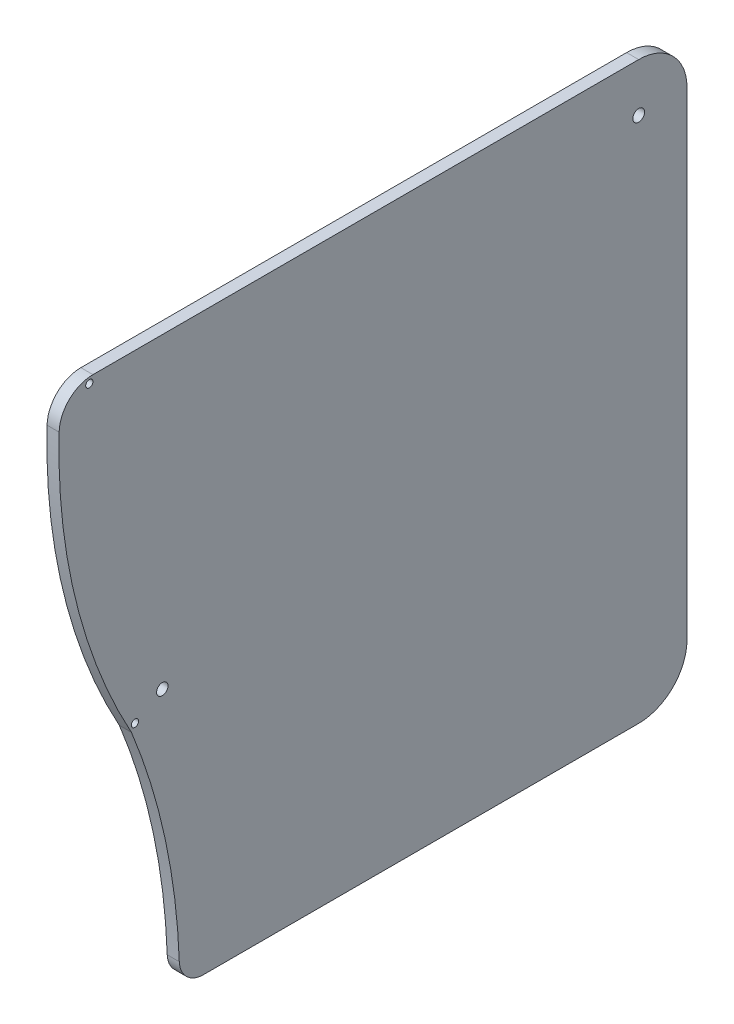
from build123d import *

# Parameters (mm, degrees)
SKETCH1_R           = 1.55
BOSS_EXTRUDE1_DEPTH = 3.175
CUT_EXTRUDE1_DEPTH  = 4.175
FILLET1_R           = 8.89
SKETCH3_R           = 1.5
CUT_EXTRUDE2_DEPTH  = 4.175
SKETCH4_R           = 0.9525
CUT_EXTRUDE3_DEPTH  = 4.175
FILLET2_R           = 6.35


with BuildPart() as part:
    # Sketch1 → Boss-Extrude1 (new body)
    with BuildSketch(Plane(origin=(0, 0, 0), x_dir=(0, 0, -1), z_dir=(1, 0, 0))):
        with BuildLine():
            Line((69.85, 75.565), (-82.55, 75.565))
            Line((-82.55, 75.565), (-82.55, -75.565))
            Line((-82.55, -75.565), (69.85, -75.565))
            ThreePointArc((69.85, -75.565), (78.830256121, -71.845256121), (82.55, -62.865))
            Line((82.55, -62.865), (82.55, 62.865))
            ThreePointArc((82.55, 62.865), (78.830256121, 71.845256121), (69.85, 75.565))
        make_face()
        with Locations((69.85, 62.865)):
            Circle(SKETCH1_R, mode=Mode.SUBTRACT)
    extrude(amount=BOSS_EXTRUDE1_DEPTH)

    # Sketch2 → Cut-Extrude1 (cut, through all)
    with BuildSketch(Plane(origin=(3.175, 0, 0), x_dir=(0, 0, -1), z_dir=(1, 0, 0))):
        with BuildLine():
            Line((-63.5, -10.915332745), (-63.5, -75.565))
            Line((-63.5, -75.565), (-50.8, -75.565))
            ThreePointArc((-50.8, -75.565), (-54.005053677, -42.622362446), (-63.5, -10.915332745))
        make_face()
        with BuildLine():
            Line((-82.55, 75.565), (-82.55, 62.865))
            ThreePointArc((-82.55, 62.865), (-82.417420191, 69.220528969), (-82.019911437, 75.565))
            Line((-82.019911437, 75.565), (-82.55, 75.565))
        make_face()
        with BuildLine():
            Line((-82.55, -75.565), (-63.5, -75.565))
            Line((-63.5, -75.565), (-63.5, -10.915332745))
            ThreePointArc((-63.5, -10.915332745), (-77.710665491, 24.765), (-82.55, 62.865))
            Line((-82.55, 62.865), (-82.55, -75.565))
        make_face()
    extrude(amount=-CUT_EXTRUDE1_DEPTH, mode=Mode.SUBTRACT)

    # Fillet1
    fillet1_edges = [part.edges().sort_by_distance(p)[0] for p in [
        (1.5875, 75.565, 82.019911437),
    ]]
    fillet(fillet1_edges, radius=FILLET1_R)

    # Sketch3 → Cut-Extrude2 (cut, through all)
    with BuildSketch(Plane(origin=(3.175, 0, 0), x_dir=(0, 0, -1), z_dir=(1, 0, 0))):
        with Locations((-55.378790619, -5.135)):
            Circle(SKETCH3_R)
    extrude(amount=-CUT_EXTRUDE2_DEPTH, mode=Mode.SUBTRACT)

    # Sketch4 → Cut-Extrude3 (cut, through all)
    with BuildSketch(Plane(origin=(3.175, 0, 0), x_dir=(0, 0, -1), z_dir=(1, 0, 0))):
        with Locations((-74.561915864, 73.9775)):
            Circle(SKETCH4_R)
        with Locations((-62.57206458, -9.313350112)):
            Circle(SKETCH4_R)
    extrude(amount=-CUT_EXTRUDE3_DEPTH, mode=Mode.SUBTRACT)

    # Fillet2
    fillet2_edges = [part.edges().sort_by_distance(p)[0] for p in [
        (1.5875, -75.565, 50.8),
    ]]
    fillet(fillet2_edges, radius=FILLET2_R)


solid = part.part
